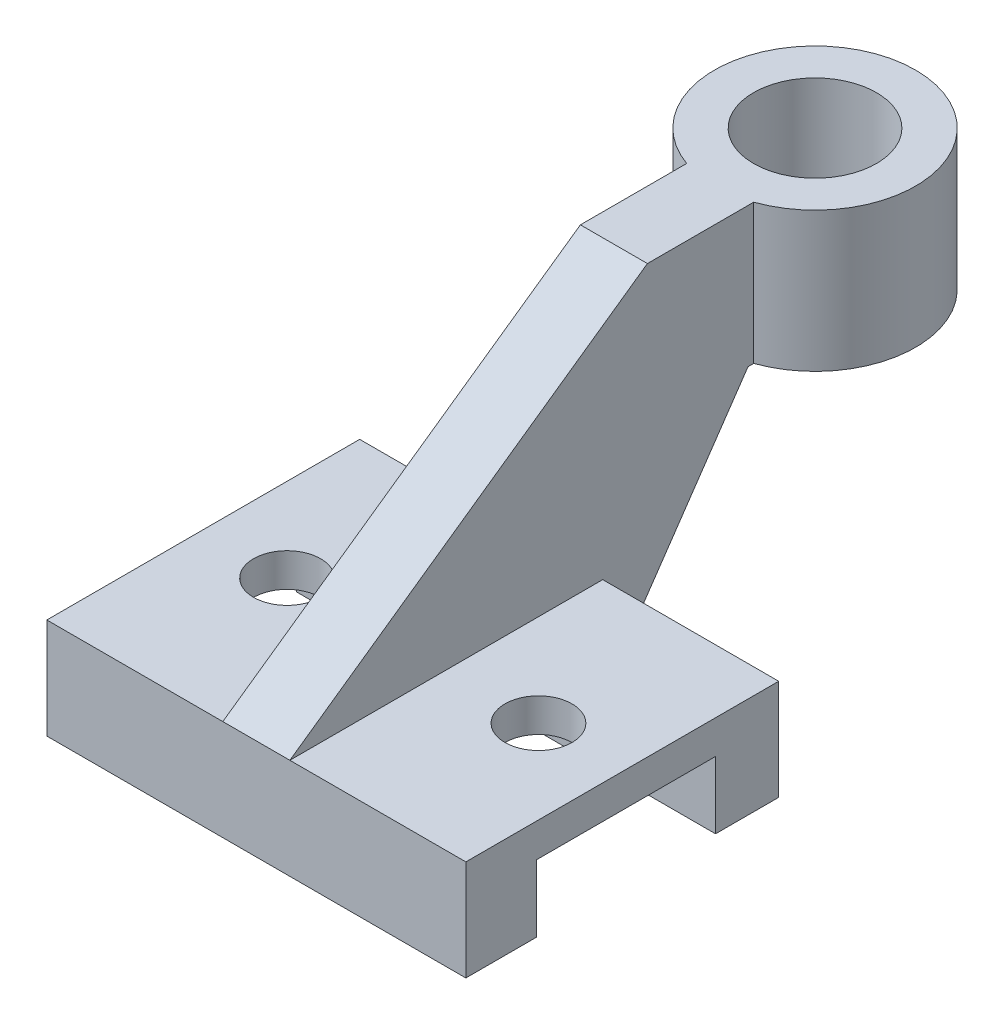
from build123d import *

# Parameters (mm, degrees)
BOSS_EXTRUDE1_DEPTH      = 1905
SKETCH6_R                = 457.2
SKETCH6_R_2              = 279.4
BOSS_EXTRUDE2_DEPTH      = 635
BOSS_EXTRUDE3_DEPTH      = 152.4
BOSS_EXTRUDE3_DEPTH_BACK = 152.4
SKETCH11_R               = 152.4
CUT_EXTRUDE1_DEPTH       = 152.4
SKETCH12_W               = 304.8
SKETCH12_H               = 635
BOSS_EXTRUDE6_DEPTH      = 152.4


with BuildPart() as part:
    # Sketch1 → Boss-Extrude1 (new body)
    with BuildSketch(Plane(origin=(0, 0, 0), x_dir=(0, 0, -1), z_dir=(1, 0, 0))):
        Polygon((-1016.531937173, -597.631413613), (-694.178010471, -597.631413613), (-694.178010471, -292.831413613), (118.621989529, -292.831413613), (118.621989529, -597.631413613), (405.868062827, -597.631413613), (405.868062827, -140.431413613), (-1016.531937173, -140.431413613), align=None)
    extrude(amount=BOSS_EXTRUDE1_DEPTH)

    # Sketch10 → Boss-Extrude3 (add, two sides)
    with BuildSketch(Plane(origin=(952.5, 0, 0), x_dir=(0, 0, -1), z_dir=(1, 0, 0))) as boss_extrude3_sk:
        Polygon((609.068062827, 1002.568586387), (-1016.531937173, -140.431413613), (405.868062827, -140.431413613), (405.868062827, -597.631413613), (1066.268062827, 367.568586387), (1066.268062827, 1002.568586387), align=None)
    extrude(amount=BOSS_EXTRUDE3_DEPTH)
    extrude(boss_extrude3_sk.sketch, amount=-BOSS_EXTRUDE3_DEPTH_BACK)

    # Sketch11 → Cut-Extrude1 (cut)
    with BuildSketch(Plane(origin=(0, -140.431413613, 0), x_dir=(1, 0, 0), z_dir=(0, 1, 0))):
        with Locations((1524, -305.331937173)):
            Circle(SKETCH11_R)
        with Locations((381, -305.331937173)):
            Circle(SKETCH11_R)
    extrude(amount=-CUT_EXTRUDE1_DEPTH, mode=Mode.SUBTRACT)



with BuildPart() as body_2:
    # Sketch6 → Boss-Extrude2 (new body)
    with BuildSketch(Plane(origin=(0, 1002.568586387, 0), x_dir=(1, 0, 0), z_dir=(0, 1, 0))):
        with Locations((952.5, 1523.468062827)):
            Circle(SKETCH6_R)
        with Locations((952.5, 1523.468062827)):
            Circle(SKETCH6_R_2, mode=Mode.SUBTRACT)
    extrude(amount=-BOSS_EXTRUDE2_DEPTH)


with BuildPart() as part_1:
    add(part.part)

    add(body_2.part)  # Boss-Extrude6 merges body 2
    # Sketch12 → Boss-Extrude6 (add)
    with BuildSketch(Plane(origin=(0, 0, -1066.268062827), x_dir=(-1, 0, 0), z_dir=(0, 0, -1))):
        with Locations((-952.5, 685.068586387)):
            Rectangle(SKETCH12_W, SKETCH12_H)
    extrude(amount=BOSS_EXTRUDE6_DEPTH)


solid = part_1.part
